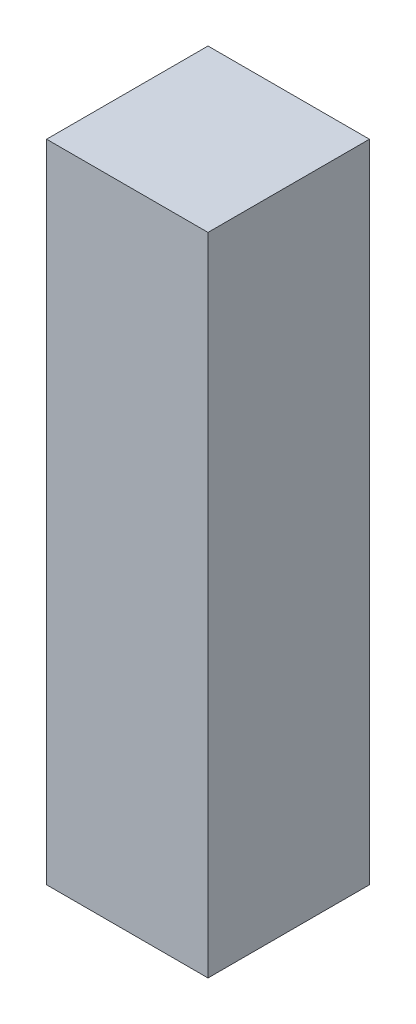
from build123d import *

# Parameters (mm, degrees)
SKETCH1_W           = 2.5
SKETCH1_H           = 2.5
BOSS_EXTRUDE1_DEPTH = 10


with BuildPart() as part:
    # Sketch1 → Boss-Extrude1 (new body)
    with BuildSketch(Plane(origin=(0, 0, 0), x_dir=(1, 0, 0), z_dir=(0, 1, 0))):
        Rectangle(SKETCH1_W, SKETCH1_H)
    extrude(amount=BOSS_EXTRUDE1_DEPTH)


solid = part.part
